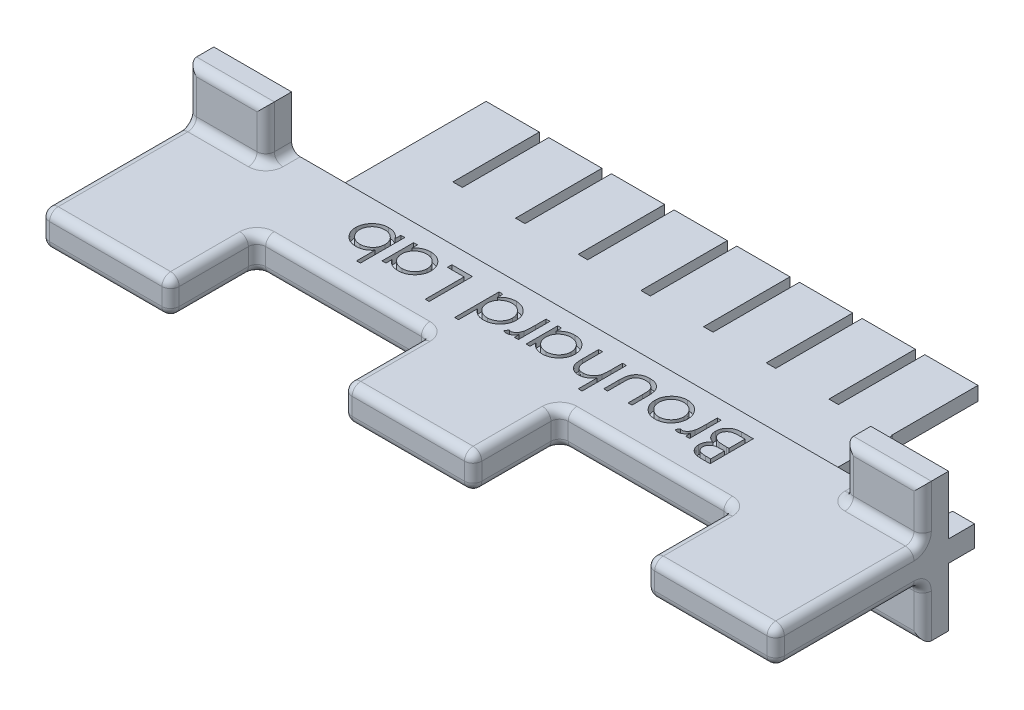
from build123d import *

# Parameters (mm, degrees)
SKETCH1_W           = 85
SKETCH1_H           = 4
BOSS_EXTRUDE1_DEPTH = 10
SKETCH2_W           = 15
SKETCH2_H           = 4
BOSS_EXTRUDE2_DEPTH = 10
SKETCH3_W           = 2.55
SKETCH3_H           = 2.45
BOSS_EXTRUDE3_DEPTH = 3
SKETCH4_W           = 57
SKETCH4_H           = 1.6
BOSS_EXTRUDE4_DEPTH = 7.5
SKETCH6_W           = 9
SKETCH6_H           = 6
BOSS_EXTRUDE6_DEPTH = 3
FILLET1_R           = 1
CUT_EXTRUDE1_DEPTH  = 1
SKETCH5_W           = 6.15
SKETCH5_H           = 1.6
BOSS_EXTRUDE5_DEPTH = 10


with BuildPart() as part:
    # Sketch1 → Boss-Extrude1 (new body)
    with BuildSketch(Plane.XY):
        Rectangle(SKETCH1_W, SKETCH1_H)
    extrude(amount=BOSS_EXTRUDE1_DEPTH)

    # Sketch2 → Boss-Extrude2 (add)
    with BuildSketch(Plane.XY.offset(10)):
        with Locations((-35, 0)):
            Rectangle(SKETCH2_W, SKETCH2_H)
        with Locations((35, 0)):
            Rectangle(SKETCH2_W, SKETCH2_H)
        Rectangle(SKETCH2_W, SKETCH2_H)
    extrude(amount=BOSS_EXTRUDE2_DEPTH)

    # Sketch3 → Boss-Extrude3 (add)
    with BuildSketch(Plane(origin=(0, 0, 0), x_dir=(-1, 0, 0), z_dir=(0, 0, -1))):
        with Locations((-41.225, 0)):
            Rectangle(SKETCH3_W, SKETCH3_H)
        with Locations((41.225, 0)):
            Rectangle(SKETCH3_W, SKETCH3_H)
    extrude(amount=BOSS_EXTRUDE3_DEPTH)

    # Sketch4 → Boss-Extrude4 (add)
    with BuildSketch(Plane(origin=(0, 0, 0), x_dir=(-1, 0, 0), z_dir=(0, 0, -1))):
        Rectangle(SKETCH4_W, SKETCH4_H)
    extrude(amount=BOSS_EXTRUDE4_DEPTH)

    # Sketch6 → Boss-Extrude6 (add)
    with BuildSketch(Plane(origin=(0, 0, 0), x_dir=(-1, 0, 0), z_dir=(0, 0, -1))):
        with Locations((38, -5)):
            Rectangle(SKETCH6_W, SKETCH6_H)
        with Locations((38, 5)):
            Rectangle(SKETCH6_W, SKETCH6_H)
        with Locations((-38, -5)):
            Rectangle(SKETCH6_W, SKETCH6_H)
        with Locations((-38, 5)):
            Rectangle(SKETCH6_W, SKETCH6_H)
    extrude(amount=-BOSS_EXTRUDE6_DEPTH)

    # Fillet1
    fillet1_edges = [part.edges().sort_by_distance(p)[0] for p in [
        (-42.5, 5, 3),
        (-38, 2, 3),
        (-33.5, 5, 3),
        (-33.5, 2, 1.5),
        (-38, 8, 3),
        (42.5, -5, 3),
        (38, -2, 3),
        (33.5, -5, 3),
        (33.5, -2, 1.5),
        (38, -8, 3),
        (42.5, 5, 3),
        (38, 8, 3),
        (33.5, 5, 3),
        (38, 2, 3),
        (33.5, 2, 1.5),
        (-17.5, -2, 10),
        (-27.5, 0, 10),
        (-27.5, -2, 15),
        (-27.5, 2, 15),
        (-42.5, 0, 20),
        (-35, -2, 20),
        (-27.5, 0, 20),
        (-35, 2, 20),
        (17.5, 2, 10),
        (27.5, 0, 10),
        (27.5, 2, 15),
        (27.5, -2, 15),
        (42.5, 0, 20),
        (35, 2, 20),
        (27.5, 0, 20),
        (35, -2, 20),
        (17.5, -2, 10),
        (-17.5, 2, 10),
        (7.5, 0, 10),
        (7.5, -2, 15),
        (7.5, 2, 15),
        (-7.5, 0, 10),
        (-7.5, 2, 15),
        (-7.5, -2, 15),
        (7.5, 0, 20),
        (0, 2, 20),
        (-7.5, 0, 20),
        (0, -2, 20),
        (42.5, -2, 11.5),
        (-42.5, -2, 11.5),
        (-42.5, 2, 11.5),
        (42.5, 2, 11.5),
        (-42.5, -5, 3),
        (-38, -8, 3),
        (-33.5, -5, 3),
        (-38, -2, 3),
        (-33.5, -2, 1.5),
    ]]
    fillet(fillet1_edges, radius=FILLET1_R)

    # Sketch8 → Cut-Extrude1 (cut)
    with BuildSketch(Plane(origin=(0, 2, 0), x_dir=(1, 0, 0), z_dir=(0, 1, 0))):
        with BuildLine():
            Line((21.955128205, -7.045024133), (20.979567308, -7.045024133))
            add(Edge.make_bspline(
                [(20.979567308, -7.045024133), (20.931811586, -7.044777014), (20.839249111, -7.044298035), (20.704660144, -7.036696988), (20.578554958, -7.026592114), (20.461156398, -7.009641733), (20.351700568, -6.992066423), (20.251298675, -6.966270076), (20.159109728, -6.937777071), (20.048409672, -6.893936716), (19.92280529, -6.825852091), (19.787804083, -6.724876123), (19.670452795, -6.603814091), (19.570669416, -6.465854357), (19.490591132, -6.314083016), (19.43339094, -6.151765477), (19.396643358, -5.981632539), (19.392911608, -5.864990679), (19.391025641, -5.806041761)],
                knots=[0, 0, 0, 0, 0.000143243, 0.000277641, 0.000404323, 0.000522601, 0.000633422, 0.000736665, 0.000833282, 0.000922745, 0.001093491, 0.001260157, 0.001426607, 0.001597303, 0.001769346, 0.001939468, 0.002112331, 0.002288957, 0.002288957, 0.002288957, 0.002288957], degree=3))
            add(Edge.make_bspline(
                [(19.391025641, -5.806041761), (19.392566125, -5.750816773), (19.395593321, -5.642294463), (19.425166581, -5.484100137), (19.4698067, -5.333038737), (19.534225102, -5.190566035), (19.616363978, -5.057933935), (19.716298264, -4.937404803), (19.834792937, -4.831345021), (19.923759393, -4.772321243), (19.968950321, -4.742339838)],
                knots=[0, 0, 0, 0, 0.00016551, 0.000325243, 0.000481139, 0.000637145, 0.000792791, 0.000947835, 0.001105294, 0.001267844, 0.001267844, 0.001267844, 0.001267844], degree=3))
            add(Edge.make_bspline(
                [(19.968950321, -4.742339838), (19.912145679, -4.720542475), (19.803464327, -4.678838718), (19.653711211, -4.604821394), (19.524645211, -4.524933301), (19.41460302, -4.438588883), (19.32239544, -4.34296875), (19.240253224, -4.240591123), (19.170541651, -4.127890536), (19.111062126, -4.007309158), (19.063944891, -3.879485542), (19.031238978, -3.745375962), (19.010496783, -3.606499394), (19.007784363, -3.512111636), (19.006410256, -3.464294967)],
                knots=[0, 0, 0, 0, 0.000182459, 0.00034909, 0.000500276, 0.000637148, 0.000767471, 0.00089793, 0.001030217, 0.001164151, 0.001300726, 0.001437979, 0.001577644, 0.001721044, 0.001721044, 0.001721044, 0.001721044], degree=3))
            add(Edge.make_bspline(
                [(19.006410256, -3.464294967), (19.007805885, -3.41548523), (19.010551822, -3.319450707), (19.030807012, -3.178370784), (19.065112767, -3.043553694), (19.112331393, -2.914102037), (19.173883248, -2.790773975), (19.248244287, -2.672600284), (19.337493216, -2.561332318), (19.437996289, -2.45535544), (19.550128803, -2.358444164), (19.673690061, -2.2751618), (19.805513315, -2.203227398), (19.947403728, -2.145396174), (20.098354491, -2.100124903), (20.258400966, -2.068824422), (20.427452272, -2.047649449), (20.543467886, -2.045914087), (20.602964744, -2.045024133)],
                knots=[0, 0, 0, 0, 0.000146402, 0.00028805, 0.000426518, 0.000563092, 0.000700608, 0.000839267, 0.000981145, 0.001127794, 0.001276955, 0.001424748, 0.00157399, 0.001726698, 0.001883553, 0.002046002, 0.002215459, 0.002393845, 0.002393845, 0.002393845, 0.002393845], degree=3))
            Line((20.602964744, -2.045024133), (21.955128205, -2.045024133))
            Line((21.955128205, -2.045024133), (21.955128205, -7.045024133))
        make_face()
        with BuildLine():
            Line((21.506410256, -6.53220362), (21.506410256, -4.929639518))
            Line((21.506410256, -4.929639518), (21.204927885, -4.929639518))
            add(Edge.make_bspline(
                [(21.204927885, -4.929639518), (21.16085778, -4.930206082), (21.075705357, -4.9313008), (20.952063514, -4.934535484), (20.837581625, -4.943196106), (20.731865233, -4.952356158), (20.635622811, -4.966460704), (20.548532434, -4.983720889), (20.469810894, -5.00181496), (20.379071632, -5.032675643), (20.276157749, -5.077807077), (20.16721677, -5.149562501), (20.069164992, -5.232639769), (19.988277934, -5.331182392), (19.920936523, -5.437599512), (19.875598165, -5.552684686), (19.843986577, -5.672472047), (19.841172407, -5.755083607), (19.83974359, -5.797027338)],
                knots=[0, 0, 0, 0, 0.000132227, 0.000255489, 0.000370952, 0.000476596, 0.000573767, 0.000662554, 0.000742964, 0.000815812, 0.000949851, 0.001078759, 0.001205868, 0.001333854, 0.001459773, 0.001581973, 0.001703679, 0.001829203, 0.001829203, 0.001829203, 0.001829203], degree=3))
            add(Edge.make_bspline(
                [(19.83974359, -5.797027338), (19.840440447, -5.824795004), (19.841807408, -5.879264312), (19.85469429, -5.958622966), (19.872478035, -6.034141042), (19.901807859, -6.103782707), (19.936556119, -6.169993364), (19.98109509, -6.230681546), (20.03245262, -6.287491301), (20.092329064, -6.338899898), (20.160479658, -6.385396007), (20.239063252, -6.424101797), (20.325943351, -6.458499162), (20.422931675, -6.48457317), (20.528096305, -6.507209559), (20.643041681, -6.521483941), (20.767075062, -6.530654029), (20.853013063, -6.531675569), (20.897435897, -6.53220362)],
                knots=[0, 0, 0, 0, 8.3229e-05, 0.000163264, 0.000240757, 0.000315341, 0.000389283, 0.000464617, 0.000540481, 0.000618594, 0.000700823, 0.000787274, 0.000880832, 0.000980716, 0.001088168, 0.001203335, 0.00132786, 0.001461107, 0.001461107, 0.001461107, 0.001461107], degree=3))
            Line((20.897435897, -6.53220362), (21.506410256, -6.53220362))
        make_face(mode=Mode.SUBTRACT)
        with BuildLine():
            Line((21.506410256, -4.416819005), (21.506410256, -2.557844646))
            Line((21.506410256, -2.557844646), (20.867387821, -2.557844646))
            add(Edge.make_bspline(
                [(20.867387821, -2.557844646), (20.82165107, -2.558445571), (20.733499514, -2.559603775), (20.606126985, -2.562352033), (20.48869926, -2.57254806), (20.380238634, -2.582323383), (20.281246941, -2.598293401), (20.190761319, -2.61375789), (20.110848501, -2.63651465), (20.017345889, -2.667828353), (19.912764158, -2.717871803), (19.798555972, -2.791464981), (19.697962318, -2.881106895), (19.612615651, -2.984324471), (19.541653639, -3.095395221), (19.492561941, -3.214537751), (19.460753316, -3.337772506), (19.457007017, -3.422035912), (19.455128205, -3.464294967)],
                knots=[0, 0, 0, 0, 0.000137234, 0.000264501, 0.000382034, 0.000490767, 0.000591058, 0.000682796, 0.000765899, 0.000840017, 0.000978463, 0.001112367, 0.001246451, 0.001380849, 0.001513136, 0.001640186, 0.001766022, 0.001892621, 0.001892621, 0.001892621, 0.001892621], degree=3))
            add(Edge.make_bspline(
                [(19.455128205, -3.464294967), (19.455511728, -3.490717987), (19.456272588, -3.543137822), (19.468232548, -3.620102651), (19.484829912, -3.695025725), (19.509289766, -3.766889341), (19.538879538, -3.836930979), (19.577915987, -3.902871611), (19.621948812, -3.967518228), (19.690148998, -4.050208407), (19.790699472, -4.144331407), (19.933635519, -4.235332182), (20.095250073, -4.309910154), (20.212743455, -4.341437989), (20.2734375, -4.357724454)],
                knots=[0, 0, 0, 0, 7.9184e-05, 0.00015709, 0.000233139, 0.000309156, 0.000384516, 0.000460796, 0.000538586, 0.000618995, 0.000781989, 0.000949233, 0.001125381, 0.001313608, 0.001313608, 0.001313608, 0.001313608], degree=3))
            add(Edge.make_bspline(
                [(20.2734375, -4.357724454), (20.297764757, -4.36266062), (20.350511268, -4.373363246), (20.436522534, -4.384653585), (20.535045896, -4.394781387), (20.645660247, -4.402076233), (20.768805516, -4.409907124), (20.904442139, -4.412844185), (21.052666008, -4.416429024), (21.15551238, -4.416685686), (21.208934295, -4.416819005)],
                knots=[0, 0, 0, 0, 7.4449e-05, 0.000161422, 0.000260089, 0.000371555, 0.000493951, 0.000630228, 0.000778496, 0.000938755, 0.000938755, 0.000938755, 0.000938755], degree=3))
            Line((21.208934295, -4.416819005), (21.506410256, -4.416819005))
        make_face(mode=Mode.SUBTRACT)
        with BuildLine():
            Line((18.237179487, -5.698870287), (17.788461538, -5.698870287))
            Line((17.788461538, -5.698870287), (17.788461538, -5.16100971))
            add(Edge.make_bspline(
                [(17.788461538, -5.16100971), (17.755359908, -5.211117117), (17.692053298, -5.306947144), (17.586273377, -5.43343718), (17.479111393, -5.53983342), (17.366921794, -5.622588498), (17.252557594, -5.685650706), (17.136357118, -5.730343447), (17.017481778, -5.757585182), (16.937237879, -5.761174556), (16.897035256, -5.762972851)],
                knots=[0, 0, 0, 0, 0.000180032, 0.00034431, 0.000493764, 0.000631989, 0.000761087, 0.000884414, 0.00100446, 0.00112499, 0.00112499, 0.00112499, 0.00112499], degree=3))
            add(Edge.make_bspline(
                [(16.897035256, -5.762972851), (16.865844687, -5.761310147), (16.801992924, -5.757906343), (16.705041331, -5.732794344), (16.604739598, -5.694222955), (16.540012887, -5.657063647), (16.506410256, -5.637772531)],
                knots=[0, 0, 0, 0, 9.3493e-05, 0.000191394, 0.000298902, 0.000414971, 0.000414971, 0.000414971, 0.000414971], degree=3))
            Line((16.506410256, -5.637772531), (16.752804487, -5.249150736))
            add(Edge.make_bspline(
                [(16.752804487, -5.249150736), (16.774388803, -5.258779687), (16.815359967, -5.277057281), (16.875295061, -5.298688724), (16.930554114, -5.311425747), (16.965759197, -5.313355343), (16.982171474, -5.314254902)],
                knots=[0, 0, 0, 0, 7.0888e-05, 0.000134558, 0.000190943, 0.000240184, 0.000240184, 0.000240184, 0.000240184], degree=3))
            add(Edge.make_bspline(
                [(16.982171474, -5.314254902), (17.018552318, -5.311962095), (17.092095887, -5.307327204), (17.199553418, -5.267726819), (17.305221395, -5.20820996), (17.387285817, -5.138004944), (17.451536641, -5.071852679), (17.497773588, -5.013639038), (17.539299542, -4.947803919), (17.579572406, -4.876841023), (17.616991286, -4.798984205), (17.65042989, -4.714102186), (17.681701622, -4.622897124), (17.699312387, -4.559480067), (17.708333333, -4.526995287)],
                knots=[0, 0, 0, 0, 0.000108839, 0.000220017, 0.000339778, 0.000471355, 0.000542193, 0.000616339, 0.000693851, 0.000775474, 0.000861039, 0.000952734, 0.001049023, 0.001150145, 0.001150145, 0.001150145, 0.001150145], degree=3))
            add(Edge.make_bspline(
                [(17.708333333, -4.526995287), (17.715105579, -4.4980295), (17.73018081, -4.433550753), (17.744447085, -4.325868753), (17.75911049, -4.198727857), (17.769124119, -4.051980366), (17.778583328, -3.885062178), (17.783808984, -3.698693379), (17.788295276, -3.492361731), (17.78840435, -3.348446216), (17.788461538, -3.272988877)],
                knots=[0, 0, 0, 0, 8.9193e-05, 0.000198547, 0.000325526, 0.000473173, 0.000639683, 0.000827079, 0.001032447, 0.001258811, 0.001258811, 0.001258811, 0.001258811], degree=3))
            Line((17.788461538, -3.272988877), (17.788461538, -2.045024133))
            Line((17.788461538, -2.045024133), (18.237179487, -2.045024133))
            Line((18.237179487, -2.045024133), (18.237179487, -5.698870287))
        make_face()
        with BuildLine():
            add(Edge.make_bspline(
                [(14.29286859, -5.762972851), (14.224307927, -5.761517291), (14.089877222, -5.758663293), (13.893032913, -5.728009819), (13.705327588, -5.681525783), (13.525956048, -5.616093456), (13.356402056, -5.530243686), (13.195151776, -5.426425769), (13.042528278, -5.303937317), (12.951070622, -5.209132095), (12.904647436, -5.16100971)],
                knots=[0, 0, 0, 0, 0.000205526, 0.000402987, 0.000596112, 0.000784972, 0.000974447, 0.001165038, 0.001359476, 0.001559909, 0.001559909, 0.001559909, 0.001559909], degree=3))
            add(Edge.make_bspline(
                [(12.904647436, -5.16100971), (12.864673216, -5.11498973), (12.785498387, -5.023840384), (12.683975931, -4.876046652), (12.59651656, -4.722989365), (12.526426616, -4.562636041), (12.471162296, -4.396386511), (12.431925587, -4.223669352), (12.408587109, -4.044865999), (12.405440013, -3.923431945), (12.403846154, -3.861931185)],
                knots=[0, 0, 0, 0, 0.000182745, 0.000361954, 0.000536876, 0.000710881, 0.000886036, 0.001061708, 0.001241475, 0.001425944, 0.001425944, 0.001425944, 0.001425944], degree=3))
            add(Edge.make_bspline(
                [(12.403846154, -3.861931185), (12.405248064, -3.800073959), (12.408018305, -3.677841197), (12.434223472, -3.497813533), (12.474982163, -3.323249495), (12.533313369, -3.154879952), (12.608110636, -2.992190127), (12.699383171, -2.835891045), (12.807770716, -2.685672654), (12.930635425, -2.542816985), (13.066416897, -2.411135675), (13.21375075, -2.296436369), (13.369848434, -2.197755629), (13.536840837, -2.119375683), (13.712350874, -2.056195988), (13.8974949, -2.012629522), (14.09210775, -1.986052796), (14.225006973, -1.982656037), (14.29286859, -1.980921569)],
                knots=[0, 0, 0, 0, 0.00018547, 0.000366497, 0.000544574, 0.000722589, 0.000900065, 0.001080956, 0.001264689, 0.001455025, 0.001645575, 0.001831106, 0.002014249, 0.002198383, 0.002383395, 0.002572886, 0.002767942, 0.002971467, 0.002971467, 0.002971467, 0.002971467], degree=3))
            add(Edge.make_bspline(
                [(14.29286859, -1.980921569), (14.361059424, -1.982670388), (14.494614618, -1.986095539), (14.689960267, -2.012431829), (14.875883807, -2.056661478), (15.052224048, -2.118593533), (15.219215773, -2.198399418), (15.37588985, -2.296052412), (15.523293198, -2.411193757), (15.65911724, -2.542801247), (15.781970535, -2.685676709), (15.890361026, -2.835889993), (15.981632796, -2.992190401), (16.056430263, -3.154879879), (16.114761415, -3.323249515), (16.155520121, -3.497813528), (16.181725284, -3.677841198), (16.184495525, -3.80007396), (16.185897436, -3.861931185)],
                knots=[0, 0, 0, 0, 0.000204526, 0.000400574, 0.000590065, 0.000776965, 0.000960195, 0.001144188, 0.00132972, 0.001520269, 0.001710605, 0.001894339, 0.00207523, 0.002252706, 0.002430721, 0.002608798, 0.002789825, 0.002975294, 0.002975294, 0.002975294, 0.002975294], degree=3))
            add(Edge.make_bspline(
                [(16.185897436, -3.861931185), (16.184296519, -3.923099043), (16.18112698, -4.044200892), (16.157756652, -4.22264832), (16.118946868, -4.394836864), (16.062916427, -4.560178538), (15.992956591, -4.720146456), (15.90637746, -4.873764934), (15.803872945, -5.02091287), (15.725005709, -5.111941341), (15.685096154, -5.158004902)],
                knots=[0, 0, 0, 0, 0.000183468, 0.000363236, 0.000538908, 0.000712162, 0.000886167, 0.001061962, 0.001240348, 0.001423094, 0.001423094, 0.001423094, 0.001423094], degree=3))
            add(Edge.make_bspline(
                [(15.685096154, -5.158004902), (15.638739114, -5.20653651), (15.547569839, -5.301982456), (15.394241809, -5.424229232), (15.233685171, -5.529446865), (15.063037498, -5.615253429), (14.883167202, -5.681407061), (14.694066814, -5.728226774), (14.496506031, -5.758527704), (14.361424213, -5.761476369), (14.29286859, -5.762972851)],
                knots=[0, 0, 0, 0, 0.00020114, 0.000395577, 0.000586713, 0.000776188, 0.000967274, 0.001160399, 0.001359841, 0.001565367, 0.001565367, 0.001565367, 0.001565367], degree=3))
        make_face()
        with BuildLine():
            add(Edge.make_bspline(
                [(14.294871795, -5.314254902), (14.343354042, -5.31287684), (14.439066976, -5.310156289), (14.579952881, -5.289466071), (14.715578773, -5.256679949), (14.84621924, -5.210117374), (14.971369132, -5.149920796), (15.091165691, -5.076401027), (15.205288814, -4.989167289), (15.312855022, -4.88995037), (15.412753003, -4.782192755), (15.499001382, -4.666286529), (15.572889716, -4.545452386), (15.633262525, -4.419007361), (15.679580189, -4.286604065), (15.712397714, -4.149000046), (15.733127199, -4.005785755), (15.735814091, -3.908409845), (15.737179487, -3.858926377)],
                knots=[0, 0, 0, 0, 0.000145402, 0.00028705, 0.000426247, 0.000563423, 0.000702299, 0.000842129, 0.000984361, 0.00113252, 0.001280679, 0.00142451, 0.001565195, 0.001704975, 0.001844039, 0.001985183, 0.002128814, 0.002277217, 0.002277217, 0.002277217, 0.002277217], degree=3))
            add(Edge.make_bspline(
                [(15.737179487, -3.858926377), (15.734890082, -3.794992084), (15.730346041, -3.668094469), (15.693206633, -3.48126298), (15.631516344, -3.301562306), (15.546449569, -3.131156088), (15.441687276, -2.973216762), (15.31918926, -2.831196974), (15.177261944, -2.710573578), (15.020738225, -2.609127271), (14.851836243, -2.5292384), (14.673387712, -2.471947456), (14.487017459, -2.435206285), (14.359480893, -2.431511347), (14.294871795, -2.429639518)],
                knots=[0, 0, 0, 0, 0.000191683, 0.000380455, 0.000568919, 0.000760186, 0.000950198, 0.001136194, 0.00132088, 0.001507019, 0.001694298, 0.001879594, 0.002068178, 0.002261801, 0.002261801, 0.002261801, 0.002261801], degree=3))
            add(Edge.make_bspline(
                [(14.294871795, -2.429639518), (14.23025898, -2.431500504), (14.102715078, -2.435174039), (13.916085515, -2.472133599), (13.737147914, -2.528989279), (13.568070317, -2.609217501), (13.411475317, -2.710190138), (13.270561459, -2.831884154), (13.147008507, -2.972843418), (13.04214248, -3.130946672), (12.958446366, -3.301827223), (12.896465966, -3.481229869), (12.859415628, -3.668102902), (12.854859565, -3.794994909), (12.852564103, -3.858926377)],
                knots=[0, 0, 0, 0, 0.000193623, 0.000382206, 0.000568456, 0.000755734, 0.000941873, 0.001125801, 0.001312456, 0.001502468, 0.001693291, 0.001881755, 0.002070527, 0.00226221, 0.00226221, 0.00226221, 0.00226221], degree=3))
            add(Edge.make_bspline(
                [(12.852564103, -3.858926377), (12.85391927, -3.908413822), (12.856586033, -4.00579756), (12.877461924, -4.148954918), (12.909764333, -4.286878115), (12.958078967, -4.418473367), (13.016348399, -4.546067931), (13.092028067, -4.665924648), (13.177874936, -4.782266279), (13.277956043, -4.889885455), (13.385510177, -4.98952979), (13.500490643, -5.076083255), (13.620342842, -5.149962779), (13.745532283, -5.210124787), (13.875877117, -5.256500729), (14.011091241, -5.289608892), (14.151353237, -5.310080851), (14.246726302, -5.312854653), (14.294871795, -5.314254902)],
                knots=[0, 0, 0, 0, 0.000148403, 0.000292034, 0.000433178, 0.000572578, 0.00071193, 0.000853138, 0.000996969, 0.001145128, 0.001293287, 0.001436317, 0.001576147, 0.001715023, 0.001852199, 0.001990424, 0.002132072, 0.002276473, 0.002276473, 0.002276473, 0.002276473], degree=3))
        make_face(mode=Mode.SUBTRACT)
        with BuildLine():
            Line((11.570512821, -5.698870287), (11.121794872, -5.698870287))
            Line((11.121794872, -5.698870287), (11.121794872, -4.004158749))
            add(Edge.make_bspline(
                [(11.121794872, -4.004158749), (11.121592151, -3.954411964), (11.121204354, -3.859248695), (11.118574439, -3.722312714), (11.112388591, -3.597431696), (11.104654555, -3.484533501), (11.094708647, -3.383637227), (11.082875275, -3.295095289), (11.069648958, -3.217903597), (11.056702224, -3.171413089), (11.05068109, -3.149791761)],
                knots=[0, 0, 0, 0, 0.000149242, 0.000285493, 0.000410838, 0.000524302, 0.000624962, 0.000714911, 0.000792314, 0.000859608, 0.000859608, 0.000859608, 0.000859608], degree=3))
            add(Edge.make_bspline(
                [(11.05068109, -3.149791761), (11.041021805, -3.122616307), (11.02190405, -3.06883037), (10.987228565, -2.991130691), (10.944327515, -2.919170094), (10.897397624, -2.850149082), (10.843207537, -2.786203671), (10.78254961, -2.72691621), (10.716500508, -2.671595092), (10.619751651, -2.6048734), (10.487494763, -2.534263345), (10.314242396, -2.472488378), (10.126045943, -2.436112097), (9.995820794, -2.431836921), (9.928886218, -2.429639518)],
                knots=[0, 0, 0, 0, 8.6516e-05, 0.000171232, 0.000254721, 0.000337515, 0.000421387, 0.00050567, 0.000591721, 0.00067952, 0.000857864, 0.001039709, 0.001229465, 0.001430146, 0.001430146, 0.001430146, 0.001430146], degree=3))
            add(Edge.make_bspline(
                [(9.928886218, -2.429639518), (9.86194316, -2.431828713), (9.732748927, -2.436053669), (9.546518851, -2.471939165), (9.375968682, -2.530483395), (9.223089747, -2.613350563), (9.088841758, -2.714376404), (8.976981124, -2.832969142), (8.884684323, -2.965323174), (8.844385248, -3.064072442), (8.82411859, -3.113734069)],
                knots=[0, 0, 0, 0, 0.000200681, 0.000387296, 0.000566586, 0.000739571, 0.000906841, 0.001068376, 0.001227003, 0.001387484, 0.001387484, 0.001387484, 0.001387484], degree=3))
            add(Edge.make_bspline(
                [(8.82411859, -3.113734069), (8.8181224, -3.1336855), (8.80486629, -3.177793242), (8.790725551, -3.252630176), (8.777460105, -3.341789135), (8.768616165, -3.446206446), (8.758522511, -3.564961319), (8.755037146, -3.698667884), (8.750059864, -3.846538026), (8.750020544, -3.950065981), (8.75, -4.004158749)],
                knots=[0, 0, 0, 0, 6.2462e-05, 0.000138088, 0.000228176, 0.000332823, 0.000452355, 0.000585662, 0.000733953, 0.000896216, 0.000896216, 0.000896216, 0.000896216], degree=3))
            Line((8.75, -4.004158749), (8.75, -5.698870287))
            Line((8.75, -5.698870287), (8.301282051, -5.698870287))
            Line((8.301282051, -5.698870287), (8.301282051, -3.920024133))
            add(Edge.make_bspline(
                [(8.301282051, -3.920024133), (8.30191531, -3.859585653), (8.303143917, -3.742326733), (8.310980731, -3.571916291), (8.324614367, -3.412799073), (8.344773775, -3.265462167), (8.369229918, -3.129870336), (8.400154934, -3.00598092), (8.437277048, -2.893621613), (8.479165629, -2.791153018), (8.528529202, -2.698158121), (8.581390514, -2.610389295), (8.640827886, -2.528135886), (8.705652894, -2.450645369), (8.777741804, -2.379798189), (8.85333008, -2.311961845), (8.93610888, -2.251321381), (9.023288539, -2.194646502), (9.117066908, -2.144351467), (9.216637391, -2.100832577), (9.321894658, -2.063022013), (9.433003103, -2.033803946), (9.549897573, -2.009153726), (9.67242881, -1.992746928), (9.800829998, -1.982271357), (9.888132562, -1.981379054), (9.932892628, -1.980921569)],
                knots=[0, 0, 0, 0, 0.000181315, 0.000351776, 0.000511647, 0.000660239, 0.000797754, 0.000924804, 0.001042946, 0.001152506, 0.001256441, 0.001358477, 0.001459659, 0.001560587, 0.001661157, 0.001762636, 0.001865001, 0.001968632, 0.00207439, 0.002183817, 0.002294379, 0.002409546, 0.002528193, 0.002652561, 0.002780158, 0.002914407, 0.002914407, 0.002914407, 0.002914407], degree=3))
            add(Edge.make_bspline(
                [(9.932892628, -1.980921569), (9.977316456, -1.981406186), (10.064613414, -1.982358504), (10.192711845, -1.992570693), (10.315507575, -2.00940504), (10.432494069, -2.033606354), (10.544142851, -2.063257518), (10.649911875, -2.100566743), (10.749934706, -2.144600485), (10.84442655, -2.194693497), (10.933073912, -2.251115088), (11.015677547, -2.313213364), (11.093710062, -2.379368112), (11.165005381, -2.451835522), (11.23008642, -2.530073038), (11.28923533, -2.613729086), (11.343463789, -2.701858176), (11.392537938, -2.79623559), (11.434697953, -2.899909467), (11.471919623, -3.014619732), (11.502363426, -3.141623289), (11.527138371, -3.28081177), (11.547069003, -3.431518969), (11.560906348, -3.594616706), (11.568643249, -3.769707694), (11.569876194, -3.890636109), (11.570512821, -3.953077018)],
                knots=[0, 0, 0, 0, 0.000133247, 0.000261843, 0.000385219, 0.000504847, 0.000620013, 0.00073152, 0.000840947, 0.000947589, 0.001052063, 0.001155829, 0.001257407, 0.001358687, 0.001460383, 0.00156238, 0.001665793, 0.001770617, 0.001881102, 0.002001148, 0.002132087, 0.002272558, 0.00242512, 0.002587985, 0.002763448, 0.002950772, 0.002950772, 0.002950772, 0.002950772], degree=3))
            Line((11.570512821, -3.953077018), (11.570512821, -5.698870287))
        make_face()
        with BuildLine():
            Line((7.275641026, -7.173229261), (6.826923077, -7.173229261))
            Line((6.826923077, -7.173229261), (6.826923077, -5.00876612))
            add(Edge.make_bspline(
                [(6.826923077, -5.00876612), (6.778678808, -5.068888094), (6.684893793, -5.185762911), (6.528113976, -5.339904506), (6.36474826, -5.471196487), (6.193410264, -5.578408978), (6.014828183, -5.661579829), (5.828563194, -5.719766634), (5.635090167, -5.756050633), (5.503296595, -5.760649137), (5.436698718, -5.762972851)],
                knots=[0, 0, 0, 0, 0.000231093, 0.000449235, 0.000658061, 0.000858722, 0.001054107, 0.001247341, 0.001442817, 0.001642498, 0.001642498, 0.001642498, 0.001642498], degree=3))
            add(Edge.make_bspline(
                [(5.436698718, -5.762972851), (5.369051259, -5.760620551), (5.236582495, -5.756014225), (5.044402774, -5.715426657), (4.863656734, -5.651196128), (4.696758785, -5.560924861), (4.546286047, -5.448841659), (4.415775284, -5.31738737), (4.306291209, -5.168293369), (4.233038251, -5.029320354), (4.185028125, -4.905733149), (4.154679673, -4.799671692), (4.128934509, -4.68150037), (4.106507375, -4.551264166), (4.091559078, -4.408342759), (4.079552578, -4.253379458), (4.071014758, -4.086383599), (4.070683898, -3.970783239), (4.070512821, -3.91100971)],
                knots=[0, 0, 0, 0, 0.000202742, 0.000397014, 0.000586474, 0.000776485, 0.000963986, 0.001147421, 0.001330122, 0.001516953, 0.001616837, 0.001727454, 0.0018475, 0.00197956, 0.002123683, 0.002278397, 0.002445857, 0.002625155, 0.002625155, 0.002625155, 0.002625155], degree=3))
            Line((4.070512821, -3.91100971), (4.070512821, -2.045024133))
            Line((4.070512821, -2.045024133), (4.519230769, -2.045024133))
            Line((4.519230769, -2.045024133), (4.519230769, -3.763774133))
            add(Edge.make_bspline(
                [(4.519230769, -3.763774133), (4.519501544, -3.813520868), (4.52001949, -3.908677905), (4.521752659, -4.044914373), (4.525533642, -4.16814974), (4.531869413, -4.278639822), (4.53824468, -4.376234881), (4.547283145, -4.46109433), (4.557720701, -4.532685817), (4.567105279, -4.575778103), (4.571314103, -4.595104261)],
                knots=[0, 0, 0, 0, 0.000149242, 0.000285475, 0.000408737, 0.000519077, 0.000617484, 0.0007021, 0.000775053, 0.000834376, 0.000834376, 0.000834376, 0.000834376], degree=3))
            add(Edge.make_bspline(
                [(4.571314103, -4.595104261), (4.587558684, -4.651851981), (4.618706291, -4.760660919), (4.692549434, -4.908198617), (4.782632802, -5.035130852), (4.894290172, -5.137852366), (5.023812243, -5.21879062), (5.172428658, -5.273933897), (5.338240367, -5.309099366), (5.454866892, -5.312485195), (5.515825321, -5.314254902)],
                knots=[0, 0, 0, 0, 0.000176748, 0.000338899, 0.000492364, 0.000641202, 0.000791008, 0.00094763, 0.001114405, 0.001297029, 0.001297029, 0.001297029, 0.001297029], degree=3))
            add(Edge.make_bspline(
                [(5.515825321, -5.314254902), (5.551925349, -5.313584935), (5.623366372, -5.312259087), (5.729246241, -5.298610846), (5.8322736, -5.277055291), (5.932171925, -5.245215815), (6.029144995, -5.206505033), (6.123586995, -5.15899916), (6.21420543, -5.101559446), (6.302169918, -5.036911618), (6.384056208, -4.965394032), (6.460236741, -4.889895628), (6.528148933, -4.809503542), (6.589675418, -4.725503187), (6.642787274, -4.636743532), (6.689148815, -4.544080206), (6.728485525, -4.44739143), (6.748032228, -4.380284199), (6.7578125, -4.346706826)],
                knots=[0, 0, 0, 0, 0.000108247, 0.000214218, 0.000319711, 0.000423617, 0.000528331, 0.0006327, 0.00074025, 0.000849828, 0.000959881, 0.001066117, 0.001171281, 0.001275259, 0.001378152, 0.001481176, 0.00158589, 0.001690753, 0.001690753, 0.001690753, 0.001690753], degree=3))
            add(Edge.make_bspline(
                [(6.7578125, -4.346706826), (6.763440253, -4.322391181), (6.77570382, -4.2694044), (6.789010725, -4.182012509), (6.800921863, -4.080460549), (6.81099122, -3.964902548), (6.817167057, -3.834915059), (6.823821687, -3.691385118), (6.82629885, -3.533413659), (6.826708783, -3.423562934), (6.826923077, -3.366137915)],
                knots=[0, 0, 0, 0, 7.4853e-05, 0.000163113, 0.000264986, 0.000381603, 0.000511, 0.000655356, 0.000812636, 0.000984915, 0.000984915, 0.000984915, 0.000984915], degree=3))
            Line((6.826923077, -3.366137915), (6.826923077, -2.045024133))
            Line((6.826923077, -2.045024133), (7.275641026, -2.045024133))
            Line((7.275641026, -2.045024133), (7.275641026, -7.173229261))
        make_face()
        with BuildLine():
            Line((-0.673076923, -5.698870287), (-0.673076923, -2.045024133))
            Line((-0.673076923, -2.045024133), (-0.224358974, -2.045024133))
            Line((-0.224358974, -2.045024133), (-0.224358974, -2.677035351))
            add(Edge.make_bspline(
                [(-0.224358974, -2.677035351), (-0.173692153, -2.619914798), (-0.074668173, -2.508277549), (0.089136249, -2.361533046), (0.264203306, -2.241723382), (0.447550404, -2.144473643), (0.640596711, -2.07116495), (0.842208477, -2.019519884), (1.052227954, -1.985924035), (1.195449856, -1.982604018), (1.268028846, -1.980921569)],
                knots=[0, 0, 0, 0, 0.000228947, 0.000447457, 0.00065777, 0.000863866, 0.001068669, 0.001275649, 0.001487424, 0.001705002, 0.001705002, 0.001705002, 0.001705002], degree=3))
            add(Edge.make_bspline(
                [(1.268028846, -1.980921569), (1.33255467, -1.982673239), (1.459802451, -1.986127609), (1.646984326, -2.01293508), (1.827125421, -2.055963389), (2.000340544, -2.115878617), (2.16545602, -2.194944018), (2.323402232, -2.290624075), (2.474547798, -2.403447762), (2.616018245, -2.532931528), (2.746457503, -2.673420564), (2.860578679, -2.823701191), (2.957300092, -2.98170931), (3.03678777, -3.14740051), (3.098299504, -3.320653672), (3.141095026, -3.50134994), (3.16787361, -3.689188645), (3.17132623, -3.817102795), (3.173076923, -3.881963236)],
                knots=[0, 0, 0, 0, 0.000193519, 0.000381629, 0.000566016, 0.000748473, 0.000930368, 0.001114167, 0.001301667, 0.001495236, 0.001688742, 0.001876044, 0.002060364, 0.002243594, 0.002426383, 0.002610771, 0.002799872, 0.002994392, 0.002994392, 0.002994392, 0.002994392], degree=3))
            add(Edge.make_bspline(
                [(3.173076923, -3.881963236), (3.1712874, -3.945483083), (3.167749609, -4.071058395), (3.141381566, -4.255738336), (3.097074815, -4.43363601), (3.034777431, -4.604092418), (2.955247483, -4.767794043), (2.856862681, -4.923460082), (2.742782629, -5.073471787), (2.610949305, -5.213018547), (2.468209109, -5.341451795), (2.316217898, -5.454549666), (2.156870853, -5.549984408), (1.989848458, -5.627563574), (1.81633338, -5.689212702), (1.635007518, -5.732188081), (1.446695469, -5.757450724), (1.318853253, -5.761114455), (1.25400641, -5.762972851)],
                knots=[0, 0, 0, 0, 0.000190518, 0.000376644, 0.000558351, 0.000739594, 0.000920119, 0.001103261, 0.001291171, 0.001484625, 0.001678266, 0.00186657, 0.002052086, 0.00223446, 0.002418194, 0.002603555, 0.002792521, 0.002987041, 0.002987041, 0.002987041, 0.002987041], degree=3))
            add(Edge.make_bspline(
                [(1.25400641, -5.762972851), (1.179433695, -5.760926632), (1.03320012, -5.756914093), (0.81900525, -5.723236763), (0.616281151, -5.666868078), (0.423271915, -5.589930632), (0.242689948, -5.486323272), (0.072799241, -5.358126181), (-0.084384391, -5.202231444), (-0.176893656, -5.083637559), (-0.224358974, -5.022788556)],
                knots=[0, 0, 0, 0, 0.000223629, 0.000438526, 0.00064848, 0.000853819, 0.001060171, 0.00127111, 0.001490669, 0.00172203, 0.00172203, 0.00172203, 0.00172203], degree=3))
            Line((-0.224358974, -5.022788556), (-0.224358974, -5.698870287))
            Line((-0.224358974, -5.698870287), (-0.673076923, -5.698870287))
        make_face()
        with BuildLine():
            add(Edge.make_bspline(
                [(1.247996795, -5.314254902), (1.313587334, -5.311919162), (1.443052626, -5.307308782), (1.633135329, -5.271375167), (1.81493707, -5.211432861), (1.988162207, -5.129927244), (2.148028307, -5.025521063), (2.293274093, -4.90241808), (2.4199622, -4.759110049), (2.527080559, -4.598889493), (2.61600865, -4.428155027), (2.677375939, -4.248376808), (2.71813637, -4.064413876), (2.722279372, -3.93960414), (2.724358974, -3.876955223)],
                knots=[0, 0, 0, 0, 0.000196682, 0.000388218, 0.000577945, 0.000769701, 0.000960837, 0.001149109, 0.001339255, 0.001532603, 0.001726118, 0.001914908, 0.002101131, 0.002288816, 0.002288816, 0.002288816, 0.002288816], degree=3))
            add(Edge.make_bspline(
                [(2.724358974, -3.876955223), (2.721659394, -3.814696014), (2.716270816, -3.690421632), (2.678628159, -3.506176784), (2.612554386, -3.327571475), (2.52557156, -3.154636161), (2.41676702, -2.993220534), (2.290328958, -2.847266396), (2.144346166, -2.722265786), (1.983072348, -2.617564507), (1.811006067, -2.533340742), (1.629993631, -2.473937453), (1.443190032, -2.436430737), (1.315946515, -2.431910872), (1.252003205, -2.429639518)],
                knots=[0, 0, 0, 0, 0.000186753, 0.000372773, 0.00056129, 0.00075659, 0.000952159, 0.001143808, 0.001334144, 0.001526666, 0.001719289, 0.001907113, 0.002096868, 0.002288551, 0.002288551, 0.002288551, 0.002288551], degree=3))
            add(Edge.make_bspline(
                [(1.252003205, -2.429639518), (1.187080663, -2.432002624), (1.058284568, -2.436690656), (0.867544613, -2.472872088), (0.682784064, -2.533558691), (0.505507589, -2.61619592), (0.340640106, -2.718645983), (0.193357608, -2.839118095), (0.066119696, -2.97708118), (-0.038639755, -3.131710873), (-0.122341141, -3.29936144), (-0.181608072, -3.478428524), (-0.217604718, -3.667848043), (-0.222076425, -3.797668511), (-0.224358974, -3.86393439)],
                knots=[0, 0, 0, 0, 0.000194682, 0.000386219, 0.000580065, 0.000776779, 0.000971601, 0.00116089, 0.001345905, 0.001532593, 0.001719381, 0.001906254, 0.002096806, 0.002295487, 0.002295487, 0.002295487, 0.002295487], degree=3))
            add(Edge.make_bspline(
                [(-0.224358974, -3.86393439), (-0.222988015, -3.914416985), (-0.220289533, -4.013782709), (-0.199674743, -4.159679441), (-0.166880858, -4.29929803), (-0.120676169, -4.432791295), (-0.059958997, -4.559398956), (0.013194296, -4.680113441), (0.100284193, -4.793810311), (0.198660327, -4.90034558), (0.307556085, -4.997030357), (0.42335261, -5.082247508), (0.545758559, -5.154364667), (0.674688011, -5.212077257), (0.809147942, -5.259094257), (0.950427125, -5.290148173), (1.097101723, -5.311539529), (1.197168848, -5.313340248), (1.247996795, -5.314254902)],
                knots=[0, 0, 0, 0, 0.000151404, 0.000298012, 0.000441104, 0.000581114, 0.000720894, 0.000861579, 0.00100381, 0.001149818, 0.001295962, 0.001440002, 0.001580519, 0.001721272, 0.001863175, 0.002007015, 0.002154615, 0.002306977, 0.002306977, 0.002306977, 0.002306977], degree=3))
        make_face(mode=Mode.SUBTRACT)
        with BuildLine():
            Line((-1.570512821, -5.698870287), (-2.019230769, -5.698870287))
            Line((-2.019230769, -5.698870287), (-2.019230769, -5.16100971))
            add(Edge.make_bspline(
                [(-2.019230769, -5.16100971), (-2.052332399, -5.211117117), (-2.11563901, -5.306947144), (-2.221418931, -5.43343718), (-2.328580915, -5.53983342), (-2.440770514, -5.622588498), (-2.555134714, -5.685650706), (-2.67133519, -5.730343447), (-2.79021053, -5.757585182), (-2.870454429, -5.761174556), (-2.910657051, -5.762972851)],
                knots=[0, 0, 0, 0, 0.000180032, 0.00034431, 0.000493764, 0.000631989, 0.000761087, 0.000884414, 0.00100446, 0.00112499, 0.00112499, 0.00112499, 0.00112499], degree=3))
            add(Edge.make_bspline(
                [(-2.910657051, -5.762972851), (-2.94184762, -5.761310147), (-3.005699384, -5.757906343), (-3.102650976, -5.732794344), (-3.202952709, -5.694222955), (-3.267679421, -5.657063647), (-3.301282051, -5.637772531)],
                knots=[0, 0, 0, 0, 9.3493e-05, 0.000191394, 0.000298902, 0.000414971, 0.000414971, 0.000414971, 0.000414971], degree=3))
            Line((-3.301282051, -5.637772531), (-3.054887821, -5.249150736))
            add(Edge.make_bspline(
                [(-3.054887821, -5.249150736), (-3.033303505, -5.258779687), (-2.992332341, -5.277057281), (-2.932397246, -5.298688724), (-2.877138194, -5.311425747), (-2.84193311, -5.313355343), (-2.825520833, -5.314254902)],
                knots=[0, 0, 0, 0, 7.0888e-05, 0.000134558, 0.000190943, 0.000240184, 0.000240184, 0.000240184, 0.000240184], degree=3))
            add(Edge.make_bspline(
                [(-2.825520833, -5.314254902), (-2.78913999, -5.311962095), (-2.715596421, -5.307327204), (-2.608138889, -5.267726819), (-2.502470912, -5.20820996), (-2.420406491, -5.138004944), (-2.356155667, -5.071852679), (-2.309918719, -5.013639038), (-2.268392765, -4.947803919), (-2.228119902, -4.876841023), (-2.190701022, -4.798984205), (-2.157262418, -4.714102186), (-2.125990686, -4.622897124), (-2.10837992, -4.559480067), (-2.099358974, -4.526995287)],
                knots=[0, 0, 0, 0, 0.000108839, 0.000220017, 0.000339778, 0.000471355, 0.000542193, 0.000616339, 0.000693851, 0.000775474, 0.000861039, 0.000952734, 0.001049023, 0.001150145, 0.001150145, 0.001150145, 0.001150145], degree=3))
            add(Edge.make_bspline(
                [(-2.099358974, -4.526995287), (-2.092586729, -4.4980295), (-2.077511498, -4.433550753), (-2.063245223, -4.325868753), (-2.048581818, -4.198727857), (-2.038568188, -4.051980366), (-2.02910898, -3.885062178), (-2.023883323, -3.698693379), (-2.019397031, -3.492361731), (-2.019287958, -3.348446216), (-2.019230769, -3.272988877)],
                knots=[0, 0, 0, 0, 8.9193e-05, 0.000198547, 0.000325526, 0.000473173, 0.000639683, 0.000827079, 0.001032447, 0.001258811, 0.001258811, 0.001258811, 0.001258811], degree=3))
            Line((-2.019230769, -3.272988877), (-2.019230769, -2.045024133))
            Line((-2.019230769, -2.045024133), (-1.570512821, -2.045024133))
            Line((-1.570512821, -2.045024133), (-1.570512821, -5.698870287))
        make_face()
        with BuildLine():
            Line((-7.467948718, -7.173229261), (-7.467948718, -2.045024133))
            Line((-7.467948718, -2.045024133), (-7.019230769, -2.045024133))
            Line((-7.019230769, -2.045024133), (-7.019230769, -2.677035351))
            add(Edge.make_bspline(
                [(-7.019230769, -2.677035351), (-6.968563948, -2.619914798), (-6.869539967, -2.508277549), (-6.705735546, -2.361533046), (-6.530668489, -2.241723382), (-6.347321391, -2.144473643), (-6.154275084, -2.07116495), (-5.952663318, -2.019519884), (-5.74264384, -1.985924035), (-5.599421939, -1.982604018), (-5.526842949, -1.980921569)],
                knots=[0, 0, 0, 0, 0.000228947, 0.000447457, 0.00065777, 0.000863866, 0.001068669, 0.001275649, 0.001487424, 0.001705002, 0.001705002, 0.001705002, 0.001705002], degree=3))
            add(Edge.make_bspline(
                [(-5.526842949, -1.980921569), (-5.462317125, -1.982673239), (-5.335069344, -1.986127609), (-5.147887469, -2.01293508), (-4.967746374, -2.055963389), (-4.794531251, -2.115878617), (-4.629415775, -2.194944018), (-4.471469563, -2.290624075), (-4.320323997, -2.403447762), (-4.17885355, -2.532931528), (-4.048414292, -2.673420564), (-3.934293116, -2.823701191), (-3.837571703, -2.98170931), (-3.758084025, -3.14740051), (-3.696572291, -3.320653672), (-3.653776768, -3.50134994), (-3.626998185, -3.689188645), (-3.623545565, -3.817102795), (-3.621794872, -3.881963236)],
                knots=[0, 0, 0, 0, 0.000193519, 0.000381629, 0.000566016, 0.000748473, 0.000930368, 0.001114167, 0.001301667, 0.001495236, 0.001688742, 0.001876044, 0.002060364, 0.002243594, 0.002426383, 0.002610771, 0.002799872, 0.002994392, 0.002994392, 0.002994392, 0.002994392], degree=3))
            add(Edge.make_bspline(
                [(-3.621794872, -3.881963236), (-3.623584395, -3.945483083), (-3.627122186, -4.071058395), (-3.653490229, -4.255738336), (-3.69779698, -4.43363601), (-3.760094364, -4.604092418), (-3.839624312, -4.767794043), (-3.938009114, -4.923460082), (-4.052089166, -5.073471787), (-4.18392249, -5.213018547), (-4.326662686, -5.341451795), (-4.478653896, -5.454549666), (-4.638000942, -5.549984408), (-4.805023337, -5.627563574), (-4.978538415, -5.689212702), (-5.159864277, -5.732188081), (-5.348176326, -5.757450724), (-5.476018542, -5.761114455), (-5.540865385, -5.762972851)],
                knots=[0, 0, 0, 0, 0.000190518, 0.000376644, 0.000558351, 0.000739594, 0.000920119, 0.001103261, 0.001291171, 0.001484625, 0.001678266, 0.00186657, 0.002052086, 0.00223446, 0.002418194, 0.002603555, 0.002792521, 0.002987041, 0.002987041, 0.002987041, 0.002987041], degree=3))
            add(Edge.make_bspline(
                [(-5.540865385, -5.762972851), (-5.615472135, -5.76077313), (-5.761916895, -5.756455323), (-5.97611826, -5.719140017), (-6.179467672, -5.659410978), (-6.371957323, -5.5745689), (-6.551897612, -5.463999433), (-6.721693963, -5.33102787), (-6.878744722, -5.172311274), (-6.971688123, -5.052847362), (-7.019230769, -4.991738877)],
                knots=[0, 0, 0, 0, 0.000223681, 0.00043906, 0.00065012, 0.000858193, 0.001068105, 0.001282101, 0.001503782, 0.00173592, 0.00173592, 0.00173592, 0.00173592], degree=3))
            Line((-7.019230769, -4.991738877), (-7.019230769, -7.173229261))
            Line((-7.019230769, -7.173229261), (-7.467948718, -7.173229261))
        make_face()
        with BuildLine():
            add(Edge.make_bspline(
                [(-5.546875, -5.314254902), (-5.481284461, -5.311919162), (-5.351819169, -5.307308782), (-5.161736466, -5.271375167), (-4.979934725, -5.211432861), (-4.806709588, -5.129927244), (-4.646843488, -5.025521063), (-4.501597702, -4.90241808), (-4.374909595, -4.759110049), (-4.267791236, -4.598889493), (-4.178863145, -4.428155027), (-4.117495856, -4.248376808), (-4.076735425, -4.064413876), (-4.072592423, -3.93960414), (-4.070512821, -3.876955223)],
                knots=[0, 0, 0, 0, 0.000196682, 0.000388218, 0.000577945, 0.000769701, 0.000960837, 0.001149109, 0.001339255, 0.001532603, 0.001726118, 0.001914908, 0.002101131, 0.002288816, 0.002288816, 0.002288816, 0.002288816], degree=3))
            add(Edge.make_bspline(
                [(-4.070512821, -3.876955223), (-4.073212401, -3.814696014), (-4.078600979, -3.690421632), (-4.116243636, -3.506176784), (-4.182317409, -3.327571475), (-4.269300235, -3.154636161), (-4.378104775, -2.993220534), (-4.504542837, -2.847266396), (-4.650525629, -2.722265786), (-4.811799447, -2.617564507), (-4.983865728, -2.533340742), (-5.164878163, -2.473937453), (-5.351681763, -2.436430737), (-5.47892528, -2.431910872), (-5.54286859, -2.429639518)],
                knots=[0, 0, 0, 0, 0.000186753, 0.000372773, 0.00056129, 0.00075659, 0.000952159, 0.001143808, 0.001334144, 0.001526666, 0.001719289, 0.001907113, 0.002096868, 0.002288551, 0.002288551, 0.002288551, 0.002288551], degree=3))
            add(Edge.make_bspline(
                [(-5.54286859, -2.429639518), (-5.607791132, -2.432002624), (-5.736587227, -2.436690656), (-5.927327182, -2.472872088), (-6.11208773, -2.533558691), (-6.289364206, -2.61619592), (-6.454231689, -2.718645983), (-6.601514186, -2.839118095), (-6.728752098, -2.97708118), (-6.83351155, -3.131710873), (-6.917212936, -3.29936144), (-6.976479867, -3.478428524), (-7.012476513, -3.667848043), (-7.01694822, -3.797668511), (-7.019230769, -3.86393439)],
                knots=[0, 0, 0, 0, 0.000194682, 0.000386219, 0.000580065, 0.000776779, 0.000971601, 0.00116089, 0.001345905, 0.001532593, 0.001719381, 0.001906254, 0.002096806, 0.002295487, 0.002295487, 0.002295487, 0.002295487], degree=3))
            add(Edge.make_bspline(
                [(-7.019230769, -3.86393439), (-7.01785981, -3.914416985), (-7.015161328, -4.013782709), (-6.994546538, -4.159679441), (-6.961752653, -4.29929803), (-6.915547963, -4.432791295), (-6.854830792, -4.559398956), (-6.781677499, -4.680113441), (-6.694587602, -4.793810311), (-6.596211468, -4.90034558), (-6.48731571, -4.997030357), (-6.371519185, -5.082247508), (-6.249113236, -5.154364667), (-6.120183783, -5.212077257), (-5.985723853, -5.259094257), (-5.84444467, -5.290148173), (-5.697770072, -5.311539529), (-5.597702946, -5.313340248), (-5.546875, -5.314254902)],
                knots=[0, 0, 0, 0, 0.000151404, 0.000298012, 0.000441104, 0.000581114, 0.000720894, 0.000861579, 0.00100381, 0.001149818, 0.001295962, 0.001440002, 0.001580519, 0.001721272, 0.001863175, 0.002007015, 0.002154615, 0.002306977, 0.002306977, 0.002306977, 0.002306977], degree=3))
        make_face(mode=Mode.SUBTRACT)
        Polygon((-10.544871795, -7.045024133), (-10.993589744, -7.045024133), (-10.993589744, -2.557844646), (-12.916666667, -2.557844646), (-12.916666667, -2.045024133), (-10.544871795, -2.045024133), align=None)
        with BuildLine():
            Line((-17.33974359, -5.698870287), (-17.33974359, -2.045024133))
            Line((-17.33974359, -2.045024133), (-16.891025641, -2.045024133))
            Line((-16.891025641, -2.045024133), (-16.891025641, -2.677035351))
            add(Edge.make_bspline(
                [(-16.891025641, -2.677035351), (-16.840358819, -2.619914798), (-16.741334839, -2.508277549), (-16.577530418, -2.361533046), (-16.402463361, -2.241723382), (-16.219116263, -2.144473643), (-16.026069955, -2.07116495), (-15.82445819, -2.019519884), (-15.614438712, -1.985924035), (-15.471216811, -1.982604018), (-15.398637821, -1.980921569)],
                knots=[0, 0, 0, 0, 0.000228947, 0.000447457, 0.00065777, 0.000863866, 0.001068669, 0.001275649, 0.001487424, 0.001705002, 0.001705002, 0.001705002, 0.001705002], degree=3))
            add(Edge.make_bspline(
                [(-15.398637821, -1.980921569), (-15.334111997, -1.982673239), (-15.206864215, -1.986127609), (-15.019682341, -2.01293508), (-14.839541246, -2.055963389), (-14.666326123, -2.115878617), (-14.501210646, -2.194944018), (-14.343264435, -2.290624075), (-14.192118869, -2.403447762), (-14.050648422, -2.532931528), (-13.920209164, -2.673420564), (-13.806087987, -2.823701191), (-13.709366575, -2.98170931), (-13.629878896, -3.14740051), (-13.568367163, -3.320653672), (-13.52557164, -3.50134994), (-13.498793057, -3.689188645), (-13.495340437, -3.817102795), (-13.493589744, -3.881963236)],
                knots=[0, 0, 0, 0, 0.000193519, 0.000381629, 0.000566016, 0.000748473, 0.000930368, 0.001114167, 0.001301667, 0.001495236, 0.001688742, 0.001876044, 0.002060364, 0.002243594, 0.002426383, 0.002610771, 0.002799872, 0.002994392, 0.002994392, 0.002994392, 0.002994392], degree=3))
            add(Edge.make_bspline(
                [(-13.493589744, -3.881963236), (-13.495379267, -3.945483083), (-13.498917057, -4.071058395), (-13.525285101, -4.255738336), (-13.569591852, -4.43363601), (-13.631889236, -4.604092418), (-13.711419183, -4.767794043), (-13.809803986, -4.923460082), (-13.923884038, -5.073471787), (-14.055717362, -5.213018547), (-14.198457558, -5.341451795), (-14.350448768, -5.454549666), (-14.509795814, -5.549984408), (-14.676818209, -5.627563574), (-14.850333287, -5.689212702), (-15.031659148, -5.732188081), (-15.219971197, -5.757450724), (-15.347813414, -5.761114455), (-15.412660256, -5.762972851)],
                knots=[0, 0, 0, 0, 0.000190518, 0.000376644, 0.000558351, 0.000739594, 0.000920119, 0.001103261, 0.001291171, 0.001484625, 0.001678266, 0.00186657, 0.002052086, 0.00223446, 0.002418194, 0.002603555, 0.002792521, 0.002987041, 0.002987041, 0.002987041, 0.002987041], degree=3))
            add(Edge.make_bspline(
                [(-15.412660256, -5.762972851), (-15.487232972, -5.760926632), (-15.633466547, -5.756914093), (-15.847661417, -5.723236763), (-16.050385516, -5.666868078), (-16.243394751, -5.589930632), (-16.423976718, -5.486323272), (-16.593867425, -5.358126181), (-16.751051057, -5.202231444), (-16.843560322, -5.083637559), (-16.891025641, -5.022788556)],
                knots=[0, 0, 0, 0, 0.000223629, 0.000438526, 0.00064848, 0.000853819, 0.001060171, 0.00127111, 0.001490669, 0.00172203, 0.00172203, 0.00172203, 0.00172203], degree=3))
            Line((-16.891025641, -5.022788556), (-16.891025641, -5.698870287))
            Line((-16.891025641, -5.698870287), (-17.33974359, -5.698870287))
        make_face()
        with BuildLine():
            add(Edge.make_bspline(
                [(-15.418669872, -5.314254902), (-15.353079333, -5.311919162), (-15.223614041, -5.307308782), (-15.033531338, -5.271375167), (-14.851729596, -5.211432861), (-14.67850446, -5.129927244), (-14.51863836, -5.025521063), (-14.373392574, -4.90241808), (-14.246704467, -4.759110049), (-14.139586107, -4.598889493), (-14.050658017, -4.428155027), (-13.989290728, -4.248376808), (-13.948530296, -4.064413876), (-13.944387294, -3.93960414), (-13.942307692, -3.876955223)],
                knots=[0, 0, 0, 0, 0.000196682, 0.000388218, 0.000577945, 0.000769701, 0.000960837, 0.001149109, 0.001339255, 0.001532603, 0.001726118, 0.001914908, 0.002101131, 0.002288816, 0.002288816, 0.002288816, 0.002288816], degree=3))
            add(Edge.make_bspline(
                [(-13.942307692, -3.876955223), (-13.945007272, -3.814696014), (-13.950395851, -3.690421632), (-13.988038508, -3.506176784), (-14.05411228, -3.327571475), (-14.141095107, -3.154636161), (-14.249899647, -2.993220534), (-14.376337709, -2.847266396), (-14.5223205, -2.722265786), (-14.683594319, -2.617564507), (-14.8556606, -2.533340742), (-15.036673035, -2.473937453), (-15.223476635, -2.436430737), (-15.350720152, -2.431910872), (-15.414663462, -2.429639518)],
                knots=[0, 0, 0, 0, 0.000186753, 0.000372773, 0.00056129, 0.00075659, 0.000952159, 0.001143808, 0.001334144, 0.001526666, 0.001719289, 0.001907113, 0.002096868, 0.002288551, 0.002288551, 0.002288551, 0.002288551], degree=3))
            add(Edge.make_bspline(
                [(-15.414663462, -2.429639518), (-15.479586003, -2.432002624), (-15.608382099, -2.436690656), (-15.799122054, -2.472872088), (-15.983882602, -2.533558691), (-16.161159078, -2.61619592), (-16.326026561, -2.718645983), (-16.473309058, -2.839118095), (-16.60054697, -2.97708118), (-16.705306421, -3.131710873), (-16.789007808, -3.29936144), (-16.848274738, -3.478428524), (-16.884271385, -3.667848043), (-16.888743092, -3.797668511), (-16.891025641, -3.86393439)],
                knots=[0, 0, 0, 0, 0.000194682, 0.000386219, 0.000580065, 0.000776779, 0.000971601, 0.00116089, 0.001345905, 0.001532593, 0.001719381, 0.001906254, 0.002096806, 0.002295487, 0.002295487, 0.002295487, 0.002295487], degree=3))
            add(Edge.make_bspline(
                [(-16.891025641, -3.86393439), (-16.889654682, -3.914416985), (-16.8869562, -4.013782709), (-16.86634141, -4.159679441), (-16.833547525, -4.29929803), (-16.787342835, -4.432791295), (-16.726625663, -4.559398956), (-16.65347237, -4.680113441), (-16.566382473, -4.793810311), (-16.46800634, -4.90034558), (-16.359110582, -4.997030357), (-16.243314057, -5.082247508), (-16.120908107, -5.154364667), (-15.991978655, -5.212077257), (-15.857518725, -5.259094257), (-15.716239542, -5.290148173), (-15.569564944, -5.311539529), (-15.469497818, -5.313340248), (-15.418669872, -5.314254902)],
                knots=[0, 0, 0, 0, 0.000151404, 0.000298012, 0.000441104, 0.000581114, 0.000720894, 0.000861579, 0.00100381, 0.001149818, 0.001295962, 0.001440002, 0.001580519, 0.001721272, 0.001863175, 0.002007015, 0.002154615, 0.002306977, 0.002306977, 0.002306977, 0.002306977], degree=3))
        make_face(mode=Mode.SUBTRACT)
        with BuildLine():
            Line((-18.365384615, -2.045024133), (-18.365384615, -7.173229261))
            Line((-18.365384615, -7.173229261), (-18.814102564, -7.173229261))
            Line((-18.814102564, -7.173229261), (-18.814102564, -5.03580939))
            add(Edge.make_bspline(
                [(-18.814102564, -5.03580939), (-18.864219454, -5.09415436), (-18.962300374, -5.208337992), (-19.128654328, -5.355225042), (-19.301336177, -5.482506308), (-19.484598114, -5.58483889), (-19.67683272, -5.664940638), (-19.877834911, -5.721830012), (-20.088226661, -5.757197098), (-20.231563246, -5.761025244), (-20.304487179, -5.762972851)],
                knots=[0, 0, 0, 0, 0.000230493, 0.000451084, 0.000664049, 0.000873017, 0.001079116, 0.001287413, 0.001498511, 0.001717139, 0.001717139, 0.001717139, 0.001717139], degree=3))
            add(Edge.make_bspline(
                [(-20.304487179, -5.762972851), (-20.369011744, -5.761205096), (-20.496587804, -5.757709941), (-20.684111905, -5.731031452), (-20.864332712, -5.68814873), (-21.037289304, -5.627572927), (-21.202888339, -5.548977962), (-21.361708673, -5.453554766), (-21.512989993, -5.340415671), (-21.654479443, -5.210968908), (-21.784939706, -5.070481143), (-21.898961481, -4.92015981), (-21.995817499, -4.762689294), (-22.07373271, -4.597033933), (-22.137308459, -4.425229303), (-22.17930802, -4.244815488), (-22.206438483, -4.057400514), (-22.209819587, -3.929803412), (-22.211538462, -3.864935992)],
                knots=[0, 0, 0, 0, 0.000193519, 0.000382621, 0.000567008, 0.000748519, 0.000931319, 0.001115976, 0.001303476, 0.001497045, 0.001690551, 0.001877854, 0.002062173, 0.002244068, 0.002426252, 0.00261064, 0.002798749, 0.002993269, 0.002993269, 0.002993269, 0.002993269], degree=3))
            add(Edge.make_bspline(
                [(-22.211538462, -3.864935992), (-22.209772118, -3.801078824), (-22.206289167, -3.675162545), (-22.179687298, -3.489867465), (-22.135764063, -3.311526466), (-22.072962372, -3.140600384), (-21.99401246, -2.976286222), (-21.895282066, -2.820457073), (-21.781266352, -2.670401394), (-21.649364712, -2.530939063), (-21.506631065, -2.402034206), (-21.353896432, -2.290025827), (-21.195007972, -2.193287084), (-21.027489241, -2.116636445), (-20.85382061, -2.054635129), (-20.672141486, -2.011609856), (-20.483479732, -1.986505492), (-20.355309891, -1.982797539), (-20.290464744, -1.980921569)],
                knots=[0, 0, 0, 0, 0.000191518, 0.000377644, 0.000560323, 0.000741566, 0.000922992, 0.001106135, 0.001294044, 0.001487498, 0.00168114, 0.001870249, 0.002054905, 0.002238188, 0.002421921, 0.002607283, 0.002797241, 0.002991761, 0.002991761, 0.002991761, 0.002991761], degree=3))
            add(Edge.make_bspline(
                [(-20.290464744, -1.980921569), (-20.216226305, -1.982974158), (-20.070657672, -1.986998926), (-19.857761534, -2.020531274), (-19.656382443, -2.077112607), (-19.4648395, -2.154432367), (-19.283326778, -2.256463429), (-19.114031091, -2.385942119), (-18.954396222, -2.540609978), (-18.861767995, -2.659781537), (-18.814102564, -2.721105864)],
                knots=[0, 0, 0, 0, 0.000222629, 0.000436536, 0.000644561, 0.000848971, 0.001054829, 0.001267171, 0.001486744, 0.001719515, 0.001719515, 0.001719515, 0.001719515], degree=3))
            Line((-18.814102564, -2.721105864), (-18.814102564, -2.045024133))
            Line((-18.814102564, -2.045024133), (-18.365384615, -2.045024133))
        make_face()
        with BuildLine():
            add(Edge.make_bspline(
                [(-20.286458333, -2.429639518), (-20.352050244, -2.431973286), (-20.481518242, -2.436579774), (-20.671581113, -2.472541906), (-20.853457378, -2.532377056), (-21.026237638, -2.614208286), (-21.187191664, -2.717106692), (-21.331041871, -2.841565032), (-21.458952077, -2.984192276), (-21.566565681, -3.144326908), (-21.654010536, -3.315769808), (-21.715934207, -3.494449689), (-21.756645076, -3.67780748), (-21.760753065, -3.802288047), (-21.762820513, -3.864935992)],
                knots=[0, 0, 0, 0, 0.000196682, 0.000388218, 0.000577945, 0.000769701, 0.000960293, 0.001149216, 0.001338615, 0.001533354, 0.001726414, 0.001914259, 0.002099501, 0.002287186, 0.002287186, 0.002287186, 0.002287186], degree=3))
            add(Edge.make_bspline(
                [(-21.762820513, -3.864935992), (-21.760148488, -3.927538027), (-21.754815106, -4.052492172), (-21.716788517, -4.237469623), (-21.652493936, -4.417270791), (-21.56502435, -4.590503677), (-21.45546839, -4.75134052), (-21.328480027, -4.896671296), (-21.182858507, -5.021702872), (-21.02170277, -5.125989039), (-20.850011289, -5.211070206), (-20.669311829, -5.26942127), (-20.483371276, -5.307618412), (-20.357092051, -5.312031489), (-20.293469551, -5.314254902)],
                knots=[0, 0, 0, 0, 0.000187752, 0.000374754, 0.000563877, 0.000759176, 0.000955306, 0.001146203, 0.001336539, 0.00152906, 0.001720783, 0.001909558, 0.002097347, 0.002288031, 0.002288031, 0.002288031, 0.002288031], degree=3))
            add(Edge.make_bspline(
                [(-20.293469551, -5.314254902), (-20.228516085, -5.312032662), (-20.099596635, -5.307621967), (-19.909354604, -5.269355135), (-19.723556514, -5.210709958), (-19.545977701, -5.126544195), (-19.380564445, -5.023447469), (-19.232390679, -4.902820534), (-19.106286556, -4.763922539), (-19.000377748, -4.610133991), (-18.917469384, -4.442276446), (-18.856526097, -4.26369104), (-18.82101267, -4.074339716), (-18.81643396, -3.944877983), (-18.814102564, -3.878958428)],
                knots=[0, 0, 0, 0, 0.000194682, 0.000386405, 0.000579942, 0.000777989, 0.00097419, 0.00116348, 0.001349233, 0.001535095, 0.001721882, 0.001909075, 0.002099627, 0.002297308, 0.002297308, 0.002297308, 0.002297308], degree=3))
            add(Edge.make_bspline(
                [(-18.814102564, -3.878958428), (-18.815473197, -3.828475627), (-18.818171036, -3.7291095), (-18.838790494, -3.583215701), (-18.871567289, -3.443586373), (-18.917834175, -3.31013219), (-18.978197131, -3.183636875), (-19.052032097, -3.063690974), (-19.138665337, -2.949719274), (-19.238125071, -2.843834626), (-19.346917491, -2.747216254), (-19.462056478, -2.660984017), (-19.58488223, -2.590142285), (-19.713335412, -2.531512064), (-19.847637245, -2.48485609), (-19.988881007, -2.453730826), (-20.135565269, -2.432358935), (-20.235631063, -2.430555534), (-20.286458333, -2.429639518)],
                knots=[0, 0, 0, 0, 0.000151404, 0.000298012, 0.000441104, 0.000581114, 0.000720894, 0.000860724, 0.001002955, 0.001149645, 0.00129579, 0.001439022, 0.001580404, 0.001720246, 0.001862148, 0.002005989, 0.002153589, 0.002305951, 0.002305951, 0.002305951, 0.002305951], degree=3))
        make_face(mode=Mode.SUBTRACT)
    extrude(amount=-CUT_EXTRUDE1_DEPTH, mode=Mode.SUBTRACT)

    # Sketch5 → Boss-Extrude5 (add)
    with BuildSketch(Plane(origin=(0, 0, -7.5), x_dir=(-1, 0, 0), z_dir=(0, 0, -1))):
        with Locations((25.425, 0)):
            Rectangle(SKETCH5_W, SKETCH5_H)
        with Locations((18.175, 0)):
            Rectangle(SKETCH5_W, SKETCH5_H)
        with Locations((10.925, 0)):
            Rectangle(SKETCH5_W, SKETCH5_H)
        with Locations((3.675, 0)):
            Rectangle(SKETCH5_W, SKETCH5_H)
        with Locations((-3.575, 0)):
            Rectangle(SKETCH5_W, SKETCH5_H)
        with Locations((-10.825, 0)):
            Rectangle(SKETCH5_W, SKETCH5_H)
        with Locations((-18.075, 0)):
            Rectangle(SKETCH5_W, SKETCH5_H)
        with Locations((-25.325, 0)):
            Rectangle(SKETCH5_W, SKETCH5_H)
    extrude(amount=BOSS_EXTRUDE5_DEPTH)


solid = part.part
